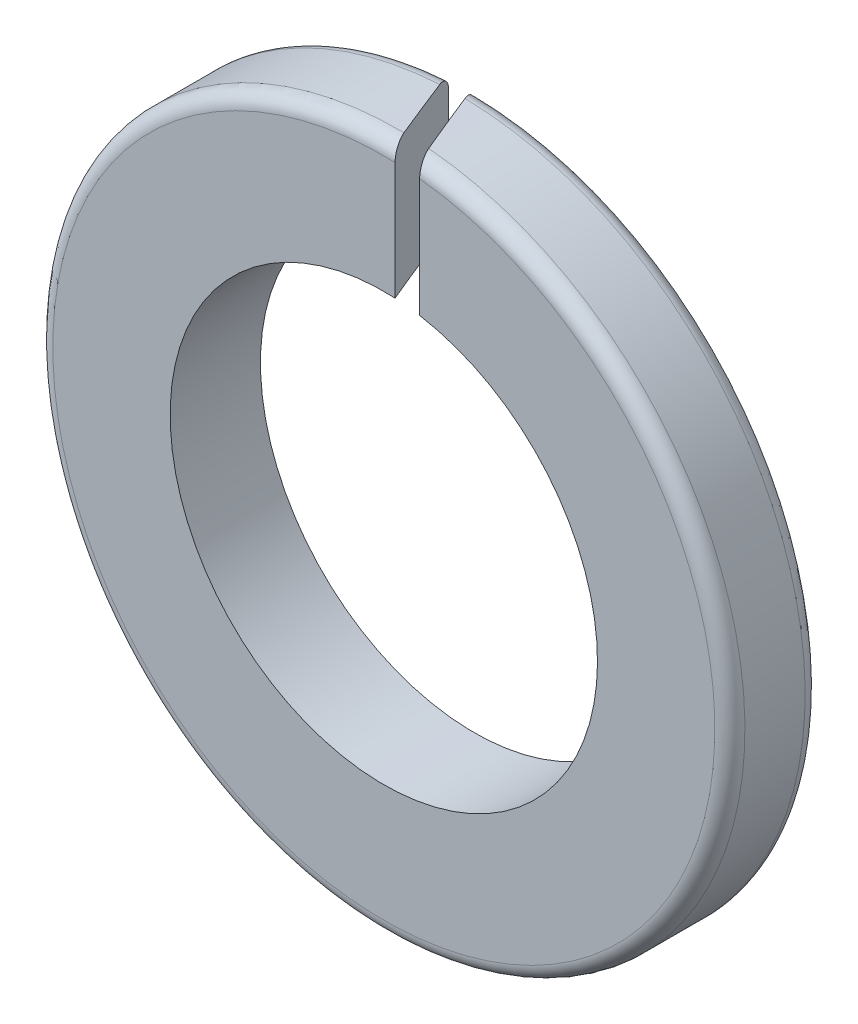
from build123d import *

# Parameters (mm, degrees)
ESQUISSE1_R             = 11.5
ESQUISSE1_R_2           = 7.1
EXTRUSION1_DEPTH        = 3
CONG_2_R                = 0.5
ENL_V_MAT_EXTRU_1_DEPTH = 12.5000001


with BuildPart() as part:
    # Esquisse1 → Extrusion1 (new body)
    with BuildSketch(Plane.XY):
        Circle(ESQUISSE1_R)
        Circle(ESQUISSE1_R_2, mode=Mode.SUBTRACT)
    extrude(amount=EXTRUSION1_DEPTH)

    # Congé2
    cong_2_edges = [part.edges().sort_by_distance(p)[0] for p in [
        (-11.5, 0, 0),
        (-11.5, 0, 3),
    ]]
    fillet(cong_2_edges, radius=CONG_2_R)

    # Esquisse2 → Enlèv. mat.-Extru.1 (cut, through all)
    with BuildSketch(Plane(origin=(0, 0, 0), x_dir=(1, 0, 0), z_dir=(0, 1, 0))):
        Polygon((-0.862634787, 2.166197843), (1.536568214, -3.872245663), (0.727848101, -3.872245663), (-1.725269573, 2.166197843), align=None)
    extrude(amount=ENL_V_MAT_EXTRU_1_DEPTH, mode=Mode.SUBTRACT)


solid = part.part
